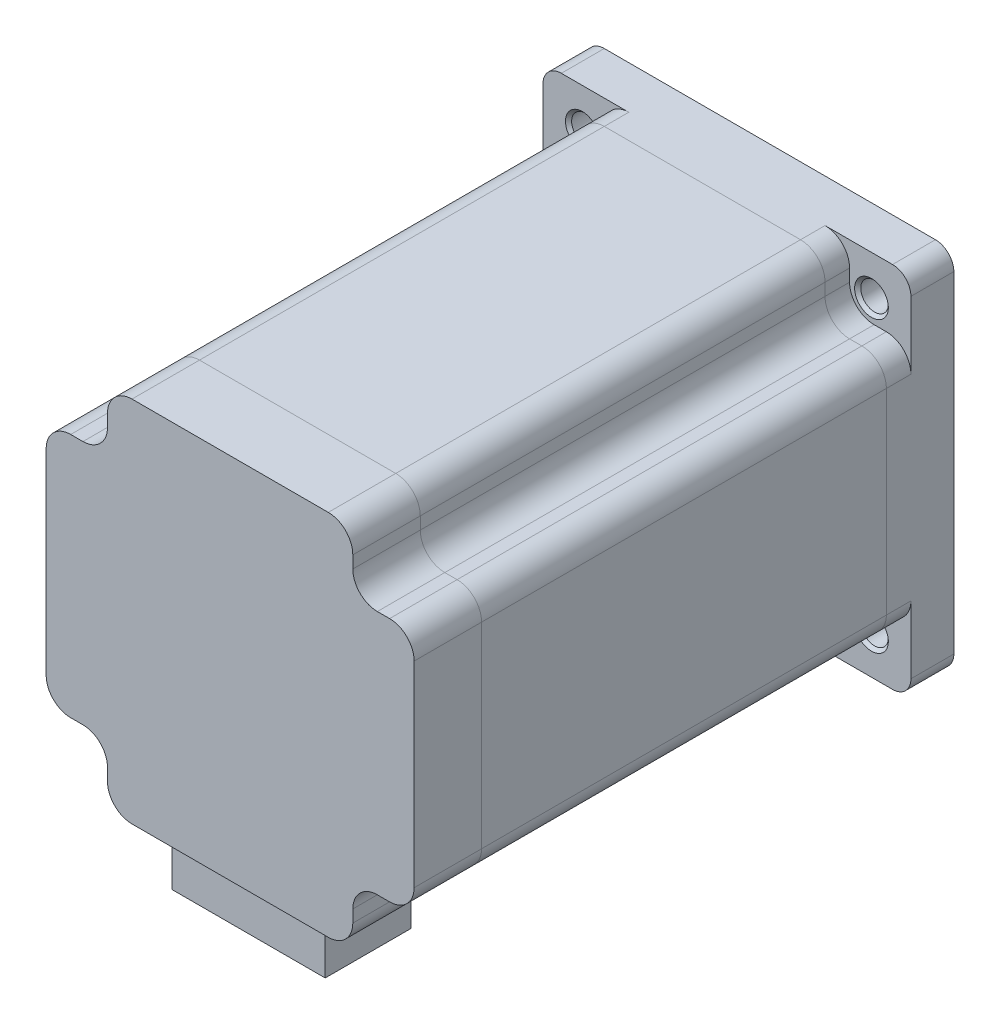
from build123d import *

# Parameters (mm, degrees)
SKETCH_1_W                  = 60
SKETCH_1_H                  = 60
EXTRUDE_1_DEPTH             = 11
SKETCH_2_W                  = 60
SKETCH_2_H                  = 60
EXTRUDE_2_DEPTH             = 66
SKETCH_3_W                  = 60
SKETCH_3_H                  = 60
EXTRUDE_3_DEPTH             = 11
SKETCH_4_R                  = 19.05
EXTRUDE_4_DEPTH             = 1.6
SKETCH_5_R                  = 5
CUT_EXTRUDE_1_DEPTH         = 5
SKETCH_6_R                  = 4
EXTRUDE_5_DEPTH             = 27.4
CUT_EXTRUDE_2_DEPTH         = 20
SKETCH_8_W                  = 10
SKETCH_8_H                  = 10
CUT_EXTRUDE_3_DEPTH         = 81
PATTERN_CIRCULAR_1_COUNT    = 4
SKETCH_11_W                 = 2.25
SKETCH_11_H                 = 31
HOLE_WIZARD_M4_1_AT_2_COUNT = 2
HOLE_WIZARD_M4_1_AT_2_PITCH = 66.66602733
HOLE_WIZARD_M4_1_AT_3_COUNT = 2
HOLE_WIZARD_M4_1_AT_3_PITCH = 47.14
HOLE_WIZARD_M4_1_AT_4_COUNT = 2
HOLE_WIZARD_M4_1_AT_4_PITCH = 47.14
CHAMFER_1_SIZE              = 0.5
FILLET_1_R                  = 3
FILLET_2_R                  = 4
FILLET_3_R                  = 4
FILLET_4_R                  = 4
SKETCH_12_W                 = 25
SKETCH_12_H                 = 14
EXTRUDE_6_DEPTH             = 9
SKETCH_13_R                 = 0.8
EXTRUDE_7_DEPTH             = 10
PATTERN_LINEAR_1_COUNT      = 5
PATTERN_LINEAR_1_PITCH      = 3
PATTERN_LINEAR_1_COL_COUNT  = 4
PATTERN_LINEAR_1_COL_PITCH  = 3


with BuildPart() as part:
    # 草圖1 → 填料-伸長1 (new body)
    with BuildSketch(Plane.XY):
        Rectangle(SKETCH_1_W, SKETCH_1_H)
    extrude(amount=EXTRUDE_1_DEPTH)

    # 草圖4 → 填料-伸長4 (add)
    with BuildSketch(Plane(origin=(0, 0, 0), x_dir=(-1, 0, 0), z_dir=(0, 0, -1))):
        Circle(SKETCH_4_R)
    extrude(amount=EXTRUDE_4_DEPTH)

    # 草圖5 → 除料-伸長1 (cut)
    with BuildSketch(Plane(origin=(0, 0, -1.6), x_dir=(-1, 0, 0), z_dir=(0, 0, -1))):
        Circle(SKETCH_5_R)
    extrude(amount=-CUT_EXTRUDE_1_DEPTH, mode=Mode.SUBTRACT)


with BuildPart() as body_2:
    # 草圖2 → 填料-伸長2 (new body)
    with BuildSketch(Plane.XY.offset(11)):
        Rectangle(SKETCH_2_W, SKETCH_2_H)
    extrude(amount=EXTRUDE_2_DEPTH)


with BuildPart() as body_3:
    # 草圖3 → 填料-伸長3 (new body)
    with BuildSketch(Plane.XY.offset(77)):
        Rectangle(SKETCH_3_W, SKETCH_3_H)
    extrude(amount=EXTRUDE_3_DEPTH)


with BuildPart() as body_4:
    # 草圖6 → 填料-伸長5 (new body)
    with BuildSketch(Plane(origin=(0, 0, 3.4), x_dir=(-1, 0, 0), z_dir=(0, 0, -1))):
        Circle(SKETCH_6_R)
    extrude(amount=EXTRUDE_5_DEPTH)

    # 草圖7 → 除料-伸長2 (cut)
    with BuildSketch(Plane(origin=(0, 0, -24), x_dir=(-1, 0, 0), z_dir=(0, 0, -1))):
        with BuildLine():
            Line((-1.936491673, 3.5), (1.936491673, 3.5))
            ThreePointArc((1.936491673, 3.5), (0, 4), (-1.936491673, 3.5))
        make_face()
    extrude(amount=-CUT_EXTRUDE_2_DEPTH, mode=Mode.SUBTRACT)


with BuildPart() as cut_extrude_3_tool:
    # 草圖8 → 除料-伸長3 (new body)
    with BuildSketch(Plane.XY.offset(88)):
        with Locations((25, 25)):
            Rectangle(SKETCH_8_W, SKETCH_8_H)
    cut_extrude_3 = extrude(amount=-CUT_EXTRUDE_3_DEPTH)


with BuildPart() as part_1:
    add(part.part)

    # 除料-伸長3: cut by cut_extrude_3_tool
    add(cut_extrude_3_tool.part, mode=Mode.SUBTRACT)


with BuildPart() as body_2_1:
    add(body_2.part)

    # 除料-伸長3: cut by cut_extrude_3_tool
    add(cut_extrude_3_tool.part, mode=Mode.SUBTRACT)


with BuildPart() as body_3_1:
    add(body_3.part)

    # 除料-伸長3: cut by cut_extrude_3_tool
    add(cut_extrude_3_tool.part, mode=Mode.SUBTRACT)


with BuildPart() as pattern_circular_1_tool:
    # 環狀複製排列1: 除料-伸長3 ×4 about axis
    pattern_circular_1_axis = Axis((0, 0, 0), (0, 0, 1))
    for i in range(1, PATTERN_CIRCULAR_1_COUNT):
        add(cut_extrude_3.rotate(pattern_circular_1_axis, i * 360 / PATTERN_CIRCULAR_1_COUNT))


with BuildPart() as part_2:
    add(part_1.part)

    # 環狀複製排列1: cut by pattern_circular_1_tool
    add(pattern_circular_1_tool.part, mode=Mode.SUBTRACT)

    # 草圖11 → M4 餘隙孔1 (revolve, cut)
    with BuildSketch(Plane(origin=(23.57, 23.57, 7), x_dir=(0, -1, 0), z_dir=(1, 0, 0))):
        with Locations((1.125, 15.5)):
            Rectangle(SKETCH_11_W, SKETCH_11_H)
    hole_wizard_m4_1 = revolve(axis=Axis((23.57, 23.57, 13.35), (0, 0, -1)), mode=Mode.SUBTRACT)

    # M4 餘隙孔1 at 2: M4 餘隙孔1 ×2
    with Locations(*[Vector(-0.707106781, -0.707106781, 0) * (i * HOLE_WIZARD_M4_1_AT_2_PITCH) for i in range(1, HOLE_WIZARD_M4_1_AT_2_COUNT)]):
        add(hole_wizard_m4_1, mode=Mode.SUBTRACT)

    # M4 餘隙孔1 at 3: M4 餘隙孔1 ×2
    with Locations(*[(-i * HOLE_WIZARD_M4_1_AT_3_PITCH, 0, 0) for i in range(1, HOLE_WIZARD_M4_1_AT_3_COUNT)]):
        add(hole_wizard_m4_1, mode=Mode.SUBTRACT)

    # M4 餘隙孔1 at 4: M4 餘隙孔1 ×2
    with Locations(*[(0, -i * HOLE_WIZARD_M4_1_AT_4_PITCH, 0) for i in range(1, HOLE_WIZARD_M4_1_AT_4_COUNT)]):
        add(hole_wizard_m4_1, mode=Mode.SUBTRACT)

    # 導角1
    chamfer_1_edges = [part_2.edges().sort_by_distance(p)[0] for p in [
        (23.57, -21.32, 0),
        (23.57, -21.32, 7),
        (-23.57, 25.82, 0),
        (-23.57, 25.82, 7),
        (-23.57, -21.32, 0),
        (-23.57, -21.32, 7),
        (23.57, 25.82, 0),
        (23.57, 25.82, 7),
    ]]
    chamfer(chamfer_1_edges, length=CHAMFER_1_SIZE)

    # 圓角1
    fillet_1_edges = [part_2.edges().sort_by_distance(p)[0] for p in [
        (30, 30, 3.5),
        (30, -30, 3.5),
        (-30, -30, 3.5),
        (-30, 30, 3.5),
    ]]
    fillet(fillet_1_edges, radius=FILLET_1_R)

    # 圓角2
    fillet_2_edges = [part_2.edges().sort_by_distance(p)[0] for p in [
        (20, 30, 9),
        (20, 20, 9),
        (30, 20, 9),
        (30, -20, 9),
        (20, -20, 9),
        (20, -30, 9),
        (-20, -30, 9),
        (-20, -20, 9),
        (-30, -20, 9),
        (-30, 20, 9),
        (-20, 20, 9),
        (-20, 30, 9),
    ]]
    fillet(fillet_2_edges, radius=FILLET_2_R)


with BuildPart() as body_2_2:
    add(body_2_1.part)

    # 環狀複製排列1: cut by pattern_circular_1_tool
    add(pattern_circular_1_tool.part, mode=Mode.SUBTRACT)

    # 圓角3
    fillet_3_edges = [body_2_2.edges().sort_by_distance(p)[0] for p in [
        (20, 30, 44),
        (20, 20, 44),
        (30, 20, 44),
        (30, -20, 44),
        (20, -20, 44),
        (20, -30, 44),
        (-20, -30, 44),
        (-20, -20, 44),
        (-30, -20, 44),
        (-30, 20, 44),
        (-20, 20, 44),
        (-20, 30, 44),
    ]]
    fillet(fillet_3_edges, radius=FILLET_3_R)


with BuildPart() as body_3_2:
    add(body_3_1.part)

    # 環狀複製排列1: cut by pattern_circular_1_tool
    add(pattern_circular_1_tool.part, mode=Mode.SUBTRACT)

    # 圓角4
    fillet_4_edges = [body_3_2.edges().sort_by_distance(p)[0] for p in [
        (20, 30, 82.5),
        (20, 20, 82.5),
        (30, 20, 82.5),
        (30, -20, 82.5),
        (20, -20, 82.5),
        (20, -30, 82.5),
        (-20, -30, 82.5),
        (-20, -20, 82.5),
        (-30, -20, 82.5),
        (-30, 20, 82.5),
        (-20, 20, 82.5),
        (-20, 30, 82.5),
    ]]
    fillet(fillet_4_edges, radius=FILLET_4_R)


with BuildPart() as body_5:
    # 草圖12 → 填料-伸長6 (new body)
    with BuildSketch(Plane.XZ.offset(30)):
        with Locations((0, 78)):
            Rectangle(SKETCH_12_W, SKETCH_12_H)
    extrude(amount=EXTRUDE_6_DEPTH)


with BuildPart() as body_6:
    # 草圖13 → 填料-伸長7 (new body)
    with BuildSketch(Plane(origin=(0, 0, 71), x_dir=(-1, 0, 0), z_dir=(0, 0, -1))):
        with Locations((1.5, -34.5)):
            Circle(SKETCH_13_R)
    extrude_7 = extrude(amount=EXTRUDE_7_DEPTH)


with BuildPart() as pattern_linear_1_1:
    # 直線複製排列1: 填料-伸長7 ×5
    with Locations(*[(i * PATTERN_LINEAR_1_PITCH, 0, 0) for i in range(1, PATTERN_LINEAR_1_COUNT)]):
        add(extrude_7)


with BuildPart() as pattern_linear_1_col_1:
    # 直線複製排列1 col: 填料-伸長7 ×4
    with Locations(*[(-i * PATTERN_LINEAR_1_COL_PITCH, 0, 0) for i in range(1, PATTERN_LINEAR_1_COL_COUNT)]):
        add(extrude_7)


solid = Compound([body_4.part, part_2.part, body_2_2.part, body_3_2.part, body_5.part, body_6.part, pattern_linear_1_1.part, pattern_linear_1_col_1.part])
